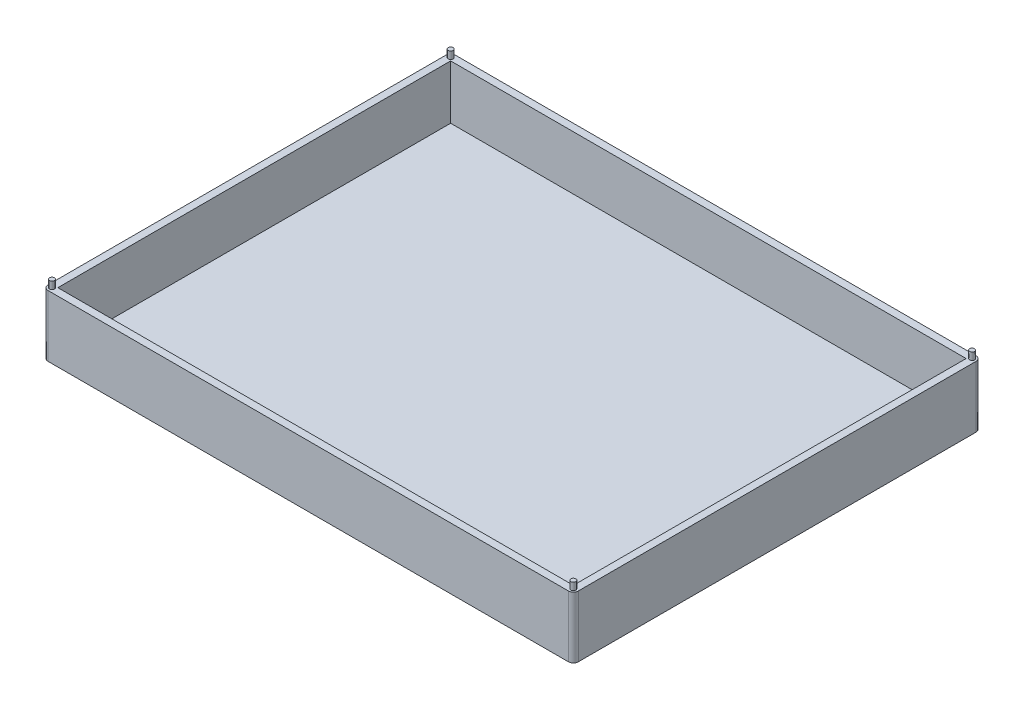
from build123d import *

# Parameters (mm, degrees)
ESQUISSE2_W         = 216
ESQUISSE2_H         = 166
ESQUISSE2_W_2       = 210
ESQUISSE2_H_2       = 160
BOSS_EXTRU_1_DEPTH  = 25
ESQUISSE4_W         = 210
ESQUISSE4_H         = 160
BOSS_EXTRU_3_DEPTH  = 3
CONG_2_R            = 2
CONG_3_R            = 2
CONG_4_R            = 2
CONG_5_R            = 2
ESQUISSE19_R        = 1
BOSS_EXTRU_8_DEPTH  = 3
ESQUISSE18_R        = 1
BOSS_EXTRU_9_DEPTH  = 3
ESQUISSE17_R        = 1
BOSS_EXTRU_10_DEPTH = 3
ESQUISSE14_R        = 1
BOSS_EXTRU_11_DEPTH = 3


with BuildPart() as part:
    # Esquisse2 → Boss.-Extru.1 (new body)
    with BuildSketch(Plane(origin=(0, 0, 0), x_dir=(1, 0, 0), z_dir=(0, 1, 0))):
        with Locations((51.031114613, -20.511820558)):
            Rectangle(ESQUISSE2_W, ESQUISSE2_H)
        with Locations((51.031114613, -20.511820558)):
            Rectangle(ESQUISSE2_W_2, ESQUISSE2_H_2, mode=Mode.SUBTRACT)
    extrude(amount=BOSS_EXTRU_1_DEPTH)

    # Esquisse4 → Boss.-Extru.3 (add)
    with BuildSketch(Plane(origin=(0, 0, 0), x_dir=(1, 0, 0), z_dir=(0, 1, 0))):
        with Locations((51.031114613, -20.511820558)):
            Rectangle(ESQUISSE4_W, ESQUISSE4_H)
    extrude(amount=BOSS_EXTRU_3_DEPTH)

    # Congé2
    cong_2_edges = [part.edges().sort_by_distance(p)[0] for p in [
        (159.031114613, 12.5, -62.488179442),
    ]]
    fillet(cong_2_edges, radius=CONG_2_R)

    # Congé3
    cong_3_edges = [part.edges().sort_by_distance(p)[0] for p in [
        (159.031114613, 12.5, 103.511820558),
    ]]
    fillet(cong_3_edges, radius=CONG_3_R)

    # Congé4
    cong_4_edges = [part.edges().sort_by_distance(p)[0] for p in [
        (-56.968885387, 12.5, 103.511820558),
    ]]
    fillet(cong_4_edges, radius=CONG_4_R)

    # Congé5
    cong_5_edges = [part.edges().sort_by_distance(p)[0] for p in [
        (-56.968885387, 12.5, -62.488179442),
    ]]
    fillet(cong_5_edges, radius=CONG_5_R)

    # Esquisse19 → Boss.-Extru.8 (add)
    with BuildSketch(Plane(origin=(0, 25, 0), x_dir=(1, 0, 0), z_dir=(0, 1, 0))):
        with Locations((-55.168885387, 60.688179442)):
            Circle(ESQUISSE19_R)
    extrude(amount=BOSS_EXTRU_8_DEPTH)

    # Esquisse18 → Boss.-Extru.9 (add)
    with BuildSketch(Plane(origin=(0, 25, 0), x_dir=(1, 0, 0), z_dir=(0, 1, 0))):
        with Locations((-55.168885387, -101.711820558)):
            Circle(ESQUISSE18_R)
    extrude(amount=BOSS_EXTRU_9_DEPTH)

    # Esquisse17 → Boss.-Extru.10 (add)
    with BuildSketch(Plane(origin=(0, 25, 0), x_dir=(1, 0, 0), z_dir=(0, 1, 0))):
        with Locations((157.231114613, -101.711820558)):
            Circle(ESQUISSE17_R)
    extrude(amount=BOSS_EXTRU_10_DEPTH)

    # Esquisse14 → Boss.-Extru.11 (add)
    with BuildSketch(Plane(origin=(0, 25, 0), x_dir=(1, 0, 0), z_dir=(0, 1, 0))):
        with Locations((157.231114613, 60.688179442)):
            Circle(ESQUISSE14_R)
    extrude(amount=BOSS_EXTRU_11_DEPTH)


solid = part.part
